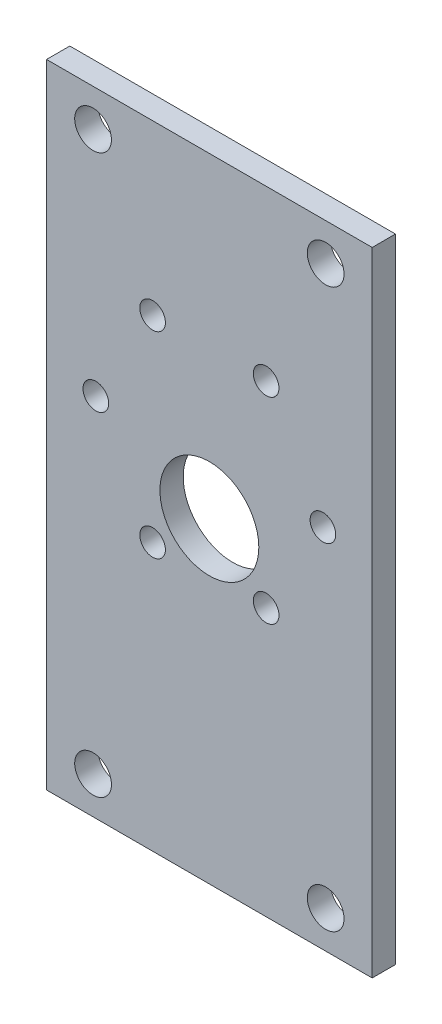
from build123d import *

# Parameters (mm, degrees)
SKETCH_1_R      = 1.75
SKETCH_1_R_2    = 6.75
SKETCH_1_R_3    = 2.50825
EXTRUDE_1_DEPTH = 3.175


with BuildPart() as part:
    # Эскиз1 → Бобышка-Вытянуть1 (new body)
    with BuildSketch(Plane.XY):
        Polygon((22.225, 86.36), (-22.225, 86.36), (-22.225, 35.56), (-22.225, 0), (22.225, 0), (22.225, 35.56), align=None)
        with Locations((-7.75, 63.353393759)):
            Circle(SKETCH_1_R, mode=Mode.SUBTRACT)
        with Locations((-15.5, 49.93)):
            Circle(SKETCH_1_R, mode=Mode.SUBTRACT)
        with Locations((-7.75, 36.506606241)):
            Circle(SKETCH_1_R, mode=Mode.SUBTRACT)
        with Locations((7.75, 36.506606241)):
            Circle(SKETCH_1_R, mode=Mode.SUBTRACT)
        with Locations((15.5, 49.93)):
            Circle(SKETCH_1_R, mode=Mode.SUBTRACT)
        with Locations((7.75, 63.353393759)):
            Circle(SKETCH_1_R, mode=Mode.SUBTRACT)
        with Locations((0, 43.18)):
            Circle(SKETCH_1_R_2, mode=Mode.SUBTRACT)
        with Locations((15.875, 81.28)):
            Circle(SKETCH_1_R_3, mode=Mode.SUBTRACT)
        with Locations((-15.875, 81.28)):
            Circle(SKETCH_1_R_3, mode=Mode.SUBTRACT)
        with Locations((15.875, 5.08)):
            Circle(SKETCH_1_R_3, mode=Mode.SUBTRACT)
        with Locations((-15.875, 5.08)):
            Circle(SKETCH_1_R_3, mode=Mode.SUBTRACT)
    extrude(amount=EXTRUDE_1_DEPTH)


solid = part.part
